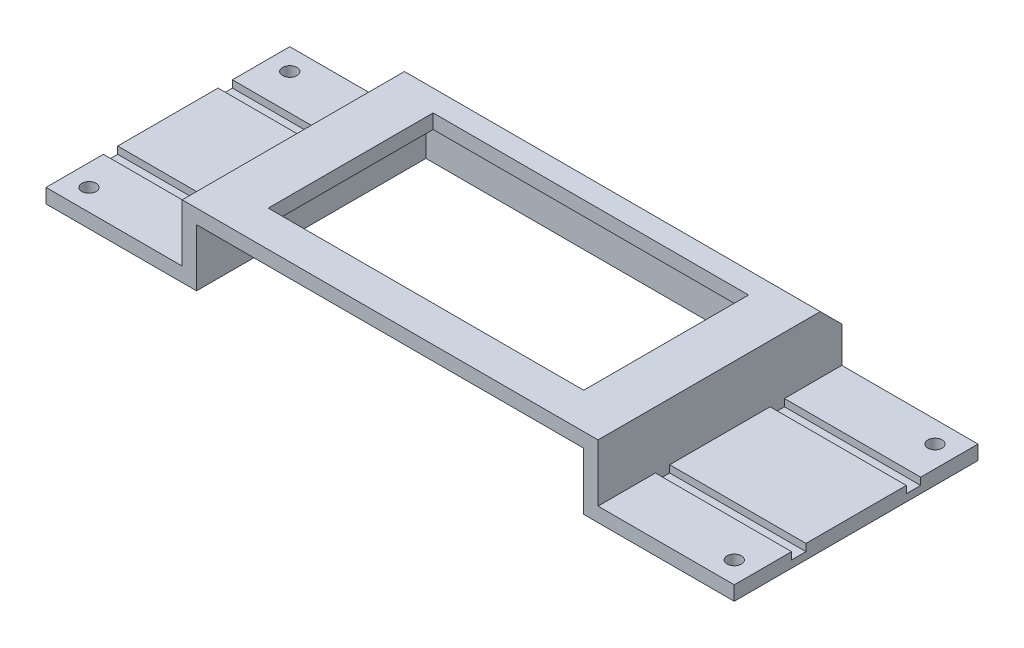
from build123d import *

# Parameters (mm, degrees)
SKETCH_1_W          = 48
SKETCH_1_H          = 17
EXTRUDE_1_DEPTH     = 1
SKETCH_2_W          = 29
SKETCH_2_H          = 17
EXTRUDE_2_DEPTH     = 4
SKETCH_3_W          = 27
SKETCH_3_H          = 16
CUT_EXTRUDE_1_DEPTH = 4
SKETCH_4_W          = 22
SKETCH_4_H          = 11.5
CUT_EXTRUDE_2_DEPTH = 6
CHAMFER_1_SIZE      = 1.5
SKETCH_5_R          = 0.5
CUT_EXTRUDE_3_DEPTH = 2
SKETCH_6_W          = 9.5
SKETCH_6_H          = 1
CUT_EXTRUDE_4_DEPTH = 0.5


with BuildPart() as part:
    # 草图1 → 凸台-拉伸1 (new body)
    with BuildSketch(Plane(origin=(0, 0, 0), x_dir=(1, 0, 0), z_dir=(0, 1, 0))):
        Rectangle(SKETCH_1_W, SKETCH_1_H)
    extrude(amount=EXTRUDE_1_DEPTH)

    # 草图2 → 凸台-拉伸2 (add)
    with BuildSketch(Plane(origin=(0, 1, 0), x_dir=(1, 0, 0), z_dir=(0, 1, 0))):
        Rectangle(SKETCH_2_W, SKETCH_2_H)
    extrude(amount=EXTRUDE_2_DEPTH)

    # 草图3 → 切除-拉伸1 (cut)
    with BuildSketch(Plane.XZ):
        with Locations((0, 0.5)):
            Rectangle(SKETCH_3_W, SKETCH_3_H)
    extrude(amount=-CUT_EXTRUDE_1_DEPTH, mode=Mode.SUBTRACT)

    # 草图4 → 切除-拉伸2 (cut, through all)
    with BuildSketch(Plane(origin=(0, 5, 0), x_dir=(1, 0, 0), z_dir=(0, 1, 0))):
        with Locations((0, -0.25)):
            Rectangle(SKETCH_4_W, SKETCH_4_H)
    extrude(amount=-CUT_EXTRUDE_2_DEPTH, mode=Mode.SUBTRACT)

    # 倒角1
    chamfer_1_edges = [part.edges().sort_by_distance(p)[0] for p in [
        (0, 5, -8.5),
    ]]
    chamfer(chamfer_1_edges, length=CHAMFER_1_SIZE)

    # 草图5 → 切除-拉伸3 (cut, through all)
    with BuildSketch(Plane(origin=(0, 1, 0), x_dir=(1, 0, 0), z_dir=(0, 1, 0))):
        with Locations((-22.5, 7)):
            Circle(SKETCH_5_R)
        with Locations((22.5, 7)):
            Circle(SKETCH_5_R)
        with Locations((22.5, -7)):
            Circle(SKETCH_5_R)
        with Locations((-22.5, -7)):
            Circle(SKETCH_5_R)
    extrude(amount=-CUT_EXTRUDE_3_DEPTH, mode=Mode.SUBTRACT)

    # 草图6 → 切除-拉伸4 (cut)
    with BuildSketch(Plane(origin=(0, 1, 0), x_dir=(1, 0, 0), z_dir=(0, 1, 0))):
        with Locations((-19.25, 4)):
            Rectangle(SKETCH_6_W, SKETCH_6_H)
        with Locations((-19.25, -4)):
            Rectangle(SKETCH_6_W, SKETCH_6_H)
        with Locations((19.25, -4)):
            Rectangle(SKETCH_6_W, SKETCH_6_H)
        with Locations((19.25, 4)):
            Rectangle(SKETCH_6_W, SKETCH_6_H)
    extrude(amount=-CUT_EXTRUDE_4_DEPTH, mode=Mode.SUBTRACT)


solid = part.part
